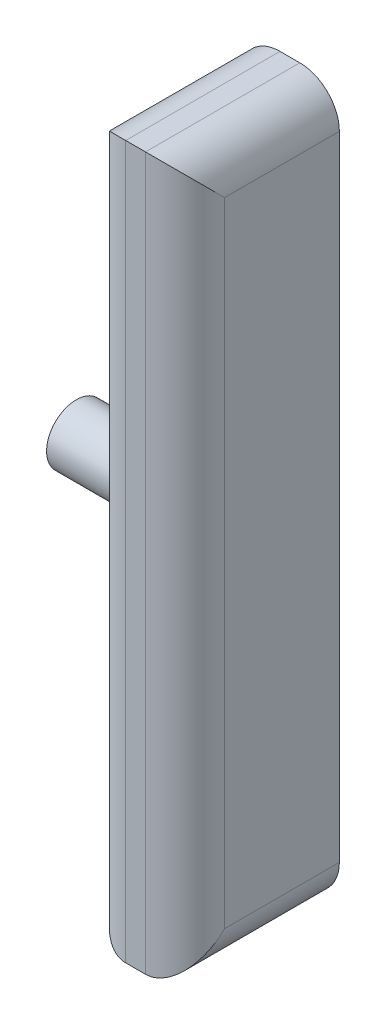
from build123d import *

# Parameters (mm, degrees)
SKETCH1_R           = 7.499999986
BOSS_EXTRUDE1_DEPTH = 22
SKETCH2_W           = 39
SKETCH2_H           = 180
BOSS_EXTRUDE2_DEPTH = 25
FILLET1_R           = 10


with BuildPart() as part:
    # Sketch1 → Boss-Extrude1 (new body)
    with BuildSketch(Plane(origin=(0, 0, 0), x_dir=(0, 0, -1), z_dir=(1, 0, 0))):
        Circle(SKETCH1_R)
    extrude(amount=BOSS_EXTRUDE1_DEPTH)

    # Sketch2 → Boss-Extrude2 (add)
    with BuildSketch(Plane(origin=(22, 0, 0), x_dir=(0, 0, -1), z_dir=(1, 0, 0))):
        Rectangle(SKETCH2_W, SKETCH2_H)
    extrude(amount=BOSS_EXTRUDE2_DEPTH)

    # Fillet1
    fillet1_edges = [part.edges().sort_by_distance(p)[0] for p in [
        (22, 0, 19.5),
        (22, -90, 0),
        (22, 90, 0),
        (47, 0, 19.5),
        (47, -90, 0),
        (47, 90, 0),
    ]]
    fillet(fillet1_edges, radius=FILLET1_R)


solid = part.part
